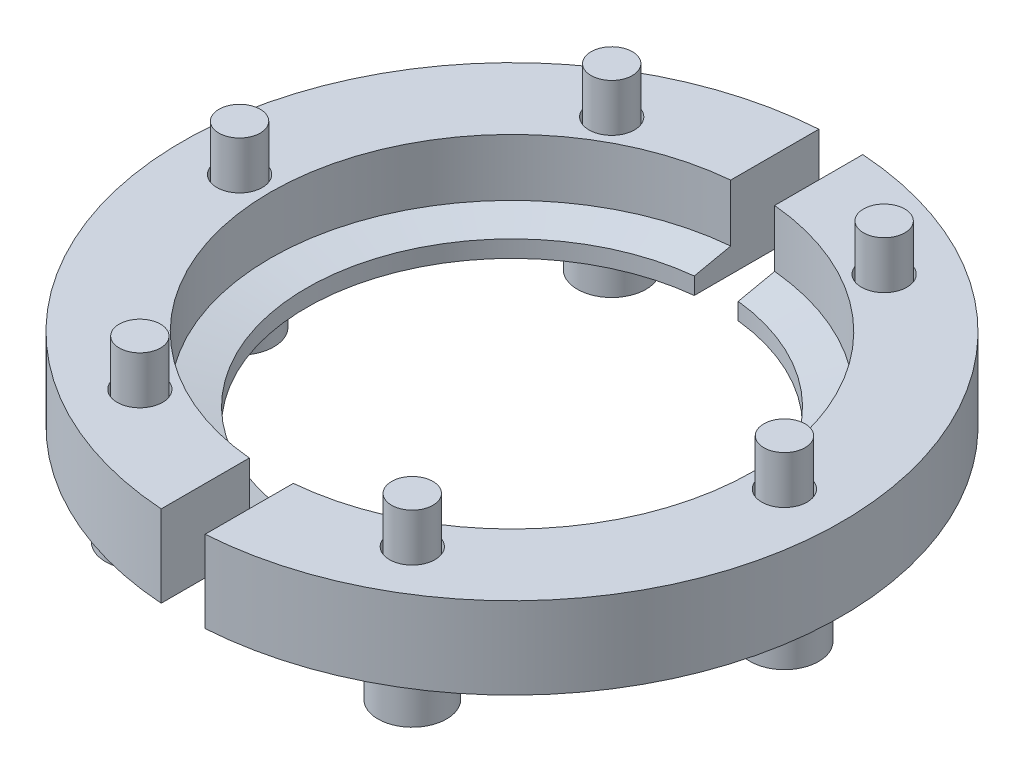
from build123d import *

# Parameters (mm, degrees)
SKETCH1_R           = 37.5
BOSS_EXTRUDE1_DEPTH = 9.3
SKETCH3_R           = 2.585
CUT_EXTRUDE1_DEPTH  = 10.3
CIRPATTERN1_COUNT   = 6
CUT_EXTRUDE2_DEPTH  = 10.3
SKETCH5_R           = 4.93
SKETCH5_R_2         = 2.7
BOSS_EXTRUDE2_DEPTH = 0.95
CUT_EXTRUDE3_DEPTH  = 3.2
CIRPATTERN2_COUNT   = 6


with BuildPart() as part:
    # Sketch1 → Boss-Extrude1 (new body)
    with BuildSketch(Plane(origin=(0, 0, 0), x_dir=(1, 0, 0), z_dir=(0, 1, 0))):
        Circle(SKETCH1_R)
    extrude(amount=BOSS_EXTRUDE1_DEPTH)

    # Sketch2 → Cut-Revolve1 (revolve, cut)
    with BuildSketch(Plane.XY):
        Polygon((23.375, 0), (23.375, 1.923204183), (27.5, 2.8), (27.5, 9.3), (0, 9.3), (0, 0), align=None)
    revolve(axis=Axis((0, 0, 0), (0, -1, 0)), mode=Mode.SUBTRACT)

    # Sketch3 → Cut-Extrude1 (cut, through all)
    with BuildSketch(Plane(origin=(0, 9.3, 0), x_dir=(1, 0, 0), z_dir=(0, 1, 0))):
        with Locations((31, 0)):
            Circle(SKETCH3_R)
    cut_extrude1 = extrude(amount=-CUT_EXTRUDE1_DEPTH, mode=Mode.SUBTRACT)

    # CirPattern1: Cut-Extrude1 ×6 about axis
    cirpattern1_axis = Axis((0, 0, 0), (0, 1, 0))
    for i in range(1, CIRPATTERN1_COUNT):
        add(cut_extrude1.rotate(cirpattern1_axis, i * 360 / CIRPATTERN1_COUNT), mode=Mode.SUBTRACT)

    # Sketch4 → Cut-Extrude2 (cut, through all)
    with BuildSketch(Plane(origin=(0, 9.3, 0), x_dir=(1, 0, 0), z_dir=(0, 1, 0))):
        with BuildLine():
            Line((-2.5, 37.416573868), (-2.5, -37.416573868))
            ThreePointArc((-2.5, -37.416573868), (0, -37.5), (2.5, -37.416573868))
            Line((2.5, -37.416573868), (2.5, 37.416573868))
            ThreePointArc((2.5, 37.416573868), (0, 37.5), (-2.5, 37.416573868))
        make_face()
    extrude(amount=-CUT_EXTRUDE2_DEPTH, mode=Mode.SUBTRACT)


with BuildPart() as body_2:
    # Sketch5 → Boss-Extrude2 (new body)
    with BuildSketch(Plane.XZ):
        with Locations((31, 0)):
            Circle(SKETCH5_R)
        with Locations((31, 0)):
            Circle(SKETCH5_R_2, mode=Mode.SUBTRACT)
    extrude(amount=BOSS_EXTRUDE2_DEPTH)


with BuildPart() as body_3:
    # Sketch7 → Revolve1 (revolve)
    with BuildSketch(Plane.XY):
        Polygon((31, 14.55), (33.35, 14.55), (33.35, -0.95), (34.9, -0.95), (34.9, -5.75), (31, -5.75), align=None)
    revolve(axis=Axis((31, 14.55, 0), (0, 1, 0)))

    # Sketch8 → Cut-Extrude3 (cut)
    with BuildSketch(Plane.XZ.offset(5.75)):
        Polygon((31, 2.33826859), (28.975, 1.169134295), (28.975, -1.169134295), (31, -2.33826859), (33.025, -1.169134295), (33.025, 1.169134295), align=None)
    extrude(amount=-CUT_EXTRUDE3_DEPTH, mode=Mode.SUBTRACT)


with BuildPart() as cirpattern2_1:
    # CirPattern2: pattern copy
    add(body_2.part.rotate(Axis((0, 0, 0), (0, 1, 0)), 1 * 360 / CIRPATTERN2_COUNT))


with BuildPart() as cirpattern2_2:
    # CirPattern2: pattern copy
    add(body_2.part.rotate(Axis((0, 0, 0), (0, 1, 0)), 2 * 360 / CIRPATTERN2_COUNT))


with BuildPart() as cirpattern2_3:
    # CirPattern2: pattern copy
    add(body_2.part.rotate(Axis((0, 0, 0), (0, 1, 0)), 3 * 360 / CIRPATTERN2_COUNT))


with BuildPart() as cirpattern2_4:
    # CirPattern2: pattern copy
    add(body_2.part.rotate(Axis((0, 0, 0), (0, 1, 0)), 4 * 360 / CIRPATTERN2_COUNT))


with BuildPart() as cirpattern2_5:
    # CirPattern2: pattern copy
    add(body_2.part.rotate(Axis((0, 0, 0), (0, 1, 0)), 5 * 360 / CIRPATTERN2_COUNT))


with BuildPart() as cirpattern2_6:
    # CirPattern2: pattern copy
    add(body_3.part.rotate(Axis((0, 0, 0), (0, 1, 0)), 1 * 360 / CIRPATTERN2_COUNT))


with BuildPart() as cirpattern2_7:
    # CirPattern2: pattern copy
    add(body_3.part.rotate(Axis((0, 0, 0), (0, 1, 0)), 2 * 360 / CIRPATTERN2_COUNT))


with BuildPart() as cirpattern2_8:
    # CirPattern2: pattern copy
    add(body_3.part.rotate(Axis((0, 0, 0), (0, 1, 0)), 3 * 360 / CIRPATTERN2_COUNT))


with BuildPart() as cirpattern2_9:
    # CirPattern2: pattern copy
    add(body_3.part.rotate(Axis((0, 0, 0), (0, 1, 0)), 4 * 360 / CIRPATTERN2_COUNT))


with BuildPart() as cirpattern2_10:
    # CirPattern2: pattern copy
    add(body_3.part.rotate(Axis((0, 0, 0), (0, 1, 0)), 5 * 360 / CIRPATTERN2_COUNT))


solid = Compound([part.part, body_2.part, body_3.part, cirpattern2_1.part, cirpattern2_2.part, cirpattern2_3.part, cirpattern2_4.part, cirpattern2_5.part, cirpattern2_6.part, cirpattern2_7.part, cirpattern2_8.part, cirpattern2_9.part, cirpattern2_10.part])
